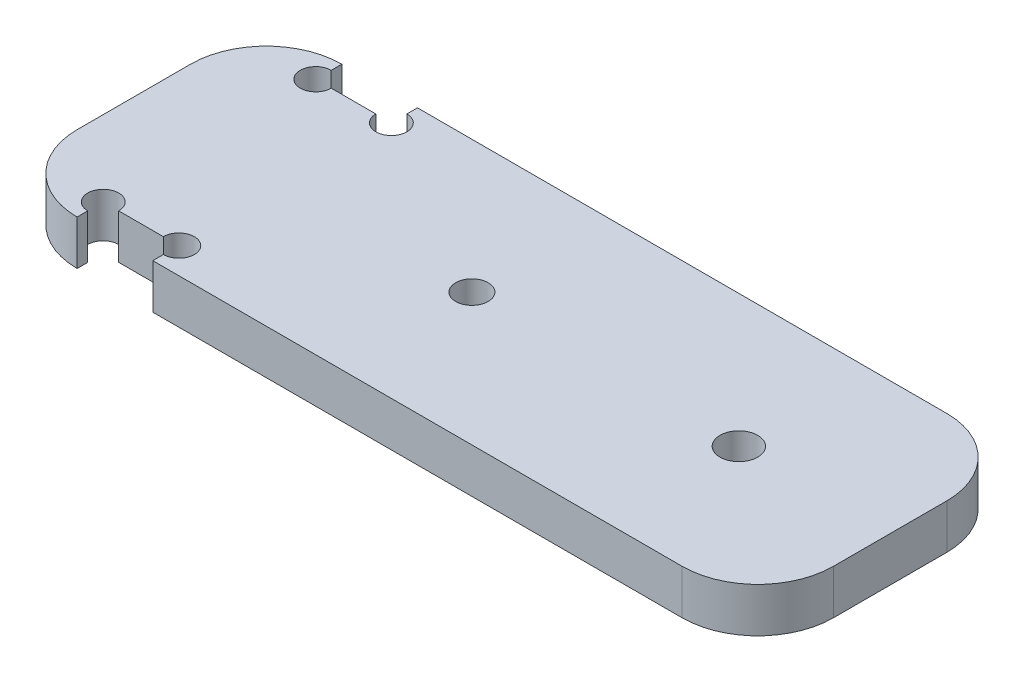
from build123d import *

# Parameters (mm, degrees)
SKETCH1_W           = 100
SKETCH1_H           = 35
BOSS_EXTRUDE1_DEPTH = 5.9
SKETCH2_R           = 2.5
CUT_EXTRUDE1_DEPTH  = 10
FILLET1_R           = 10
SKETCH4_W           = 10
SKETCH4_H           = 3.45
CUT_EXTRUDE3_DEPTH  = 10
CUT_EXTRUDE5_REACH  = 7.9
SKETCH5_R           = 2.15
CUT_EXTRUDE6_REACH  = 7.9
SKETCH6_R           = 2.05


with BuildPart() as part:
    # Sketch1 → Boss-Extrude1 (new body)
    with BuildSketch(Plane(origin=(0, 0, 0), x_dir=(1, 0, 0), z_dir=(0, 1, 0))):
        Rectangle(SKETCH1_W, SKETCH1_H)
    extrude(amount=BOSS_EXTRUDE1_DEPTH)

    # Sketch2 → Cut-Extrude1 (cut)
    with BuildSketch(Plane(origin=(0, 5.9, 0), x_dir=(1, 0, 0), z_dir=(0, 1, 0))):
        with Locations((30, 0)):
            Circle(SKETCH2_R)
    extrude(amount=-CUT_EXTRUDE1_DEPTH, mode=Mode.SUBTRACT)

    # Fillet1
    fillet1_edges = [part.edges().sort_by_distance(p)[0] for p in [
        (50, 2.95, 17.5),
        (-50, 2.95, 17.5),
        (-50, 2.95, -17.5),
        (50, 2.95, -17.5),
    ]]
    fillet(fillet1_edges, radius=FILLET1_R)

    # Sketch4 → Cut-Extrude3 (cut)
    with BuildSketch(Plane(origin=(0, 5.9, 0), x_dir=(1, 0, 0), z_dir=(0, 1, 0))):
        with Locations((-35, 15.775)):
            Rectangle(SKETCH4_W, SKETCH4_H)
        with Locations((-35, -15.775)):
            Rectangle(SKETCH4_W, SKETCH4_H)
    extrude(amount=-CUT_EXTRUDE3_DEPTH, mode=Mode.SUBTRACT)

    # Sketch5 → Cut-Extrude5 (cut, up to next)
    with BuildSketch(Plane(origin=(0, 5.9, 0), x_dir=(1, 0, 0), z_dir=(0, 1, 0)), mode=Mode.PRIVATE) as cut_extrude5_sk1:
        with Locations((-5.3, 0)):
            Circle(SKETCH5_R)
    cut_extrude5_tool1 = extrude(cut_extrude5_sk1.sketch, amount=-CUT_EXTRUDE5_REACH, mode=Mode.PRIVATE) & part.part
    add(cut_extrude5_tool1.solids().sort_by_distance((-5.3, 5.9, 0))[0], mode=Mode.SUBTRACT)

    # Sketch6 → Cut-Extrude6 (cut, up to next)
    with BuildSketch(Plane(origin=(0, 5.9, 0), x_dir=(1, 0, 0), z_dir=(0, 1, 0)), mode=Mode.PRIVATE) as cut_extrude6_sk1:
        with Locations((-40, 14.05)):
            Circle(SKETCH6_R)
    cut_extrude6_tool1 = extrude(cut_extrude6_sk1.sketch, amount=-CUT_EXTRUDE6_REACH, mode=Mode.PRIVATE) & part.part
    add(cut_extrude6_tool1.solids().sort_by_distance((-40, 5.9, -14.05))[0], mode=Mode.SUBTRACT)
    # Sketch6 → Cut-Extrude6 (cut, up to next)
    with BuildSketch(Plane(origin=(0, 5.9, 0), x_dir=(1, 0, 0), z_dir=(0, 1, 0)), mode=Mode.PRIVATE) as cut_extrude6_sk2:
        with Locations((-30, 14.05)):
            Circle(SKETCH6_R)
    cut_extrude6_tool2 = extrude(cut_extrude6_sk2.sketch, amount=-CUT_EXTRUDE6_REACH, mode=Mode.PRIVATE) & part.part
    add(cut_extrude6_tool2.solids().sort_by_distance((-30, 5.9, -14.05))[0], mode=Mode.SUBTRACT)
    # Sketch6 → Cut-Extrude6 (cut, up to next)
    with BuildSketch(Plane(origin=(0, 5.9, 0), x_dir=(1, 0, 0), z_dir=(0, 1, 0)), mode=Mode.PRIVATE) as cut_extrude6_sk3:
        with Locations((-30, -14.05)):
            Circle(SKETCH6_R)
    cut_extrude6_tool3 = extrude(cut_extrude6_sk3.sketch, amount=-CUT_EXTRUDE6_REACH, mode=Mode.PRIVATE) & part.part
    add(cut_extrude6_tool3.solids().sort_by_distance((-30, 5.9, 14.05))[0], mode=Mode.SUBTRACT)
    # Sketch6 → Cut-Extrude6 (cut, up to next)
    with BuildSketch(Plane(origin=(0, 5.9, 0), x_dir=(1, 0, 0), z_dir=(0, 1, 0)), mode=Mode.PRIVATE) as cut_extrude6_sk4:
        with Locations((-40, -14.05)):
            Circle(SKETCH6_R)
    cut_extrude6_tool4 = extrude(cut_extrude6_sk4.sketch, amount=-CUT_EXTRUDE6_REACH, mode=Mode.PRIVATE) & part.part
    add(cut_extrude6_tool4.solids().sort_by_distance((-40, 5.9, 14.05))[0], mode=Mode.SUBTRACT)


solid = part.part
